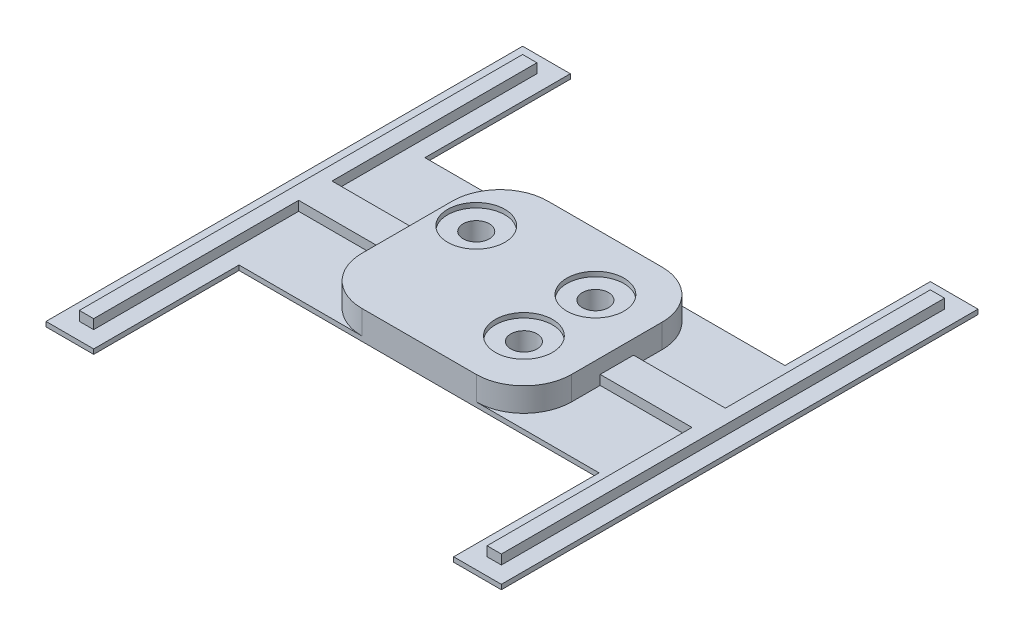
from build123d import *

# Parameters (mm, degrees)
SKETCH1_R           = 1.75
BOSS_EXTRUDE1_DEPTH = 6
SKETCH2_R           = 2.75
CUT_EXTRUDE1_DEPTH  = 5
SKETCH3_R           = 6
CUT_EXTRUDE2_DEPTH  = 1
BOSS_EXTRUDE3_DEPTH = 1
BOSS_EXTRUDE4_DEPTH = 2
SKETCH7_R           = 2
CUT_EXTRUDE3_DEPTH  = 2


with BuildPart() as part:
    # Sketch1 → Boss-Extrude1 (new body)
    with BuildSketch(Plane(origin=(0, 0, 0), x_dir=(1, 0, 0), z_dir=(0, 1, 0))):
        with BuildLine():
            Line((-11.011362906, -24.58650519), (12.988637094, -24.58650519))
            ThreePointArc((12.988637094, -24.58650519), (20.059704906, -21.657573002), (22.988637094, -14.58650519))
            Line((22.988637094, -14.58650519), (22.988637094, 4.41349481))
            ThreePointArc((22.988637094, 4.41349481), (20.059704906, 11.484562622), (12.988637094, 14.41349481))
            Line((12.988637094, 14.41349481), (-11.011362906, 14.41349481))
            ThreePointArc((-11.011362906, 14.41349481), (-18.082430717, 11.484562622), (-21.011362906, 4.41349481))
            Line((-21.011362906, 4.41349481), (-21.011362906, -14.58650519))
            ThreePointArc((-21.011362906, -14.58650519), (-18.082430717, -21.657573002), (-11.011362906, -24.58650519))
        make_face()
        with Locations((-14.011362906, 2.41349481)):
            Circle(SKETCH1_R, mode=Mode.SUBTRACT)
        with Locations((10.988637094, 2.41349481)):
            Circle(SKETCH1_R, mode=Mode.SUBTRACT)
        with Locations((10.988637094, -12.58650519)):
            Circle(SKETCH1_R, mode=Mode.SUBTRACT)
    extrude(amount=BOSS_EXTRUDE1_DEPTH)

    # Sketch2 → Cut-Extrude1 (cut)
    with BuildSketch(Plane(origin=(0, 6, 0), x_dir=(1, 0, 0), z_dir=(0, 1, 0))):
        with Locations((-14.011362906, 2.41349481)):
            Circle(SKETCH2_R)
        with Locations((10.988637094, 2.41349481)):
            Circle(SKETCH2_R)
        with Locations((10.988637094, -12.58650519)):
            Circle(SKETCH2_R)
    extrude(amount=-CUT_EXTRUDE1_DEPTH, mode=Mode.SUBTRACT)

    # Sketch3 → Cut-Extrude2 (cut)
    with BuildSketch(Plane(origin=(0, 6, 0), x_dir=(1, 0, 0), z_dir=(0, 1, 0))):
        with Locations((10.988637094, 2.41349481)):
            Circle(SKETCH3_R)
        with Locations((10.988637094, -12.58650519)):
            Circle(SKETCH3_R)
        with Locations((-14.011362906, 2.41349481)):
            Circle(SKETCH3_R)
    extrude(amount=-CUT_EXTRUDE2_DEPTH, mode=Mode.SUBTRACT)

    # Sketch4 → Boss-Extrude3 (add)
    with BuildSketch(Plane.XZ):
        Polygon((-46.776393851, -44.91349481), (-36.776393851, -44.91349481), (-36.776393851, -14.41349481), (38.75366804, -14.41349481), (38.75366804, -44.91349481), (48.75366804, -44.91349481), (48.75366804, 55.08650519), (38.75366804, 55.08650519), (38.75366804, 24.58650519), (-36.776393851, 24.58650519), (-36.776393851, 55.08650519), (-46.776393851, 55.08650519), align=None)
    extrude(amount=-BOSS_EXTRUDE3_DEPTH)

    # Sketch6 → Boss-Extrude4 (add)
    with BuildSketch(Plane(origin=(0, 1, 0), x_dir=(1, 0, 0), z_dir=(0, 1, 0))):
        Polygon((22.988637094, -1.58650519), (42.25366804, -1.58650519), (42.25366804, 41.4051813), (45.25366804, 41.4051813), (45.25366804, -51.58650519), (42.25366804, -51.58650519), (42.25366804, -8.58650519), (22.988637094, -8.58650519), align=None)
        Polygon((-21.011362906, -8.58650519), (-21.011362906, -1.58650519), (-40.276393851, -1.58650519), (-40.276393851, 41.4051813), (-43.276393851, 41.4051813), (-43.276393851, -51.58650519), (-40.276393851, -51.58650519), (-40.276393851, -8.58650519), align=None)
    extrude(amount=BOSS_EXTRUDE4_DEPTH)

    # Sketch7 → Cut-Extrude3 (cut)
    with BuildSketch(Plane.XZ):
        with Locations((-14.011362906, -2.41349481)):
            Circle(SKETCH7_R)
        with Locations((10.988637094, -2.41349481)):
            Circle(SKETCH7_R)
        with Locations((10.988637094, 12.58650519)):
            Circle(SKETCH7_R)
    extrude(amount=-CUT_EXTRUDE3_DEPTH, mode=Mode.SUBTRACT)


solid = part.part
